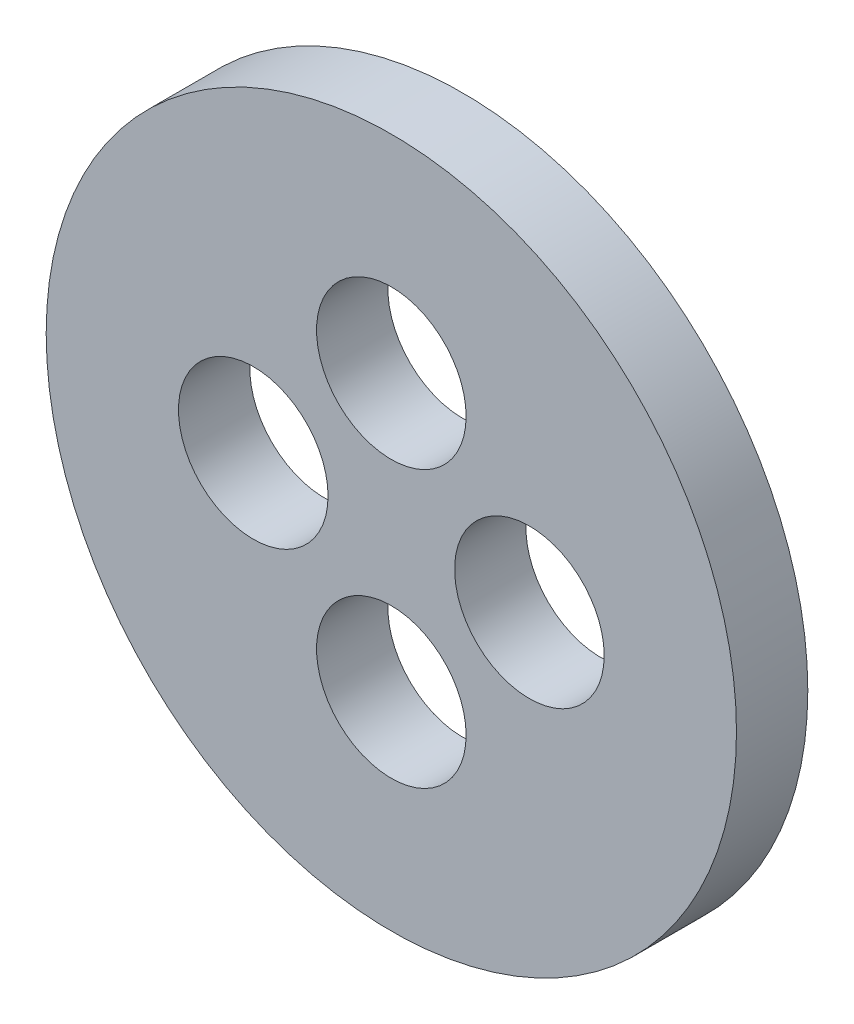
from build123d import *

# Parameters (mm, degrees)
SKETCH1_R           = 12.7
SKETCH1_R_2         = 3.25
BOSS_EXTRUDE1_DEPTH = 3.1
SKETCH2_R           = 15
SKETCH2_R_2         = 12.7
BOSS_EXTRUDE2_DEPTH = 3.1


with BuildPart() as part:
    # Sketch1 → Boss-Extrude1 (new body)
    with BuildSketch(Plane.XY):
        Circle(SKETCH1_R)
        with Locations((-6, 0)):
            Circle(SKETCH1_R_2, mode=Mode.SUBTRACT)
        with Locations((0, 6)):
            Circle(SKETCH1_R_2, mode=Mode.SUBTRACT)
        with Locations((6, 0)):
            Circle(SKETCH1_R_2, mode=Mode.SUBTRACT)
        with Locations((0, -6)):
            Circle(SKETCH1_R_2, mode=Mode.SUBTRACT)
    extrude(amount=BOSS_EXTRUDE1_DEPTH)

    # Sketch2 → Boss-Extrude2 (add, through all)
    with BuildSketch(Plane.XY.offset(3.1)):
        Circle(SKETCH2_R)
        Circle(SKETCH2_R_2, mode=Mode.SUBTRACT)
    extrude(amount=-BOSS_EXTRUDE2_DEPTH)


solid = part.part
